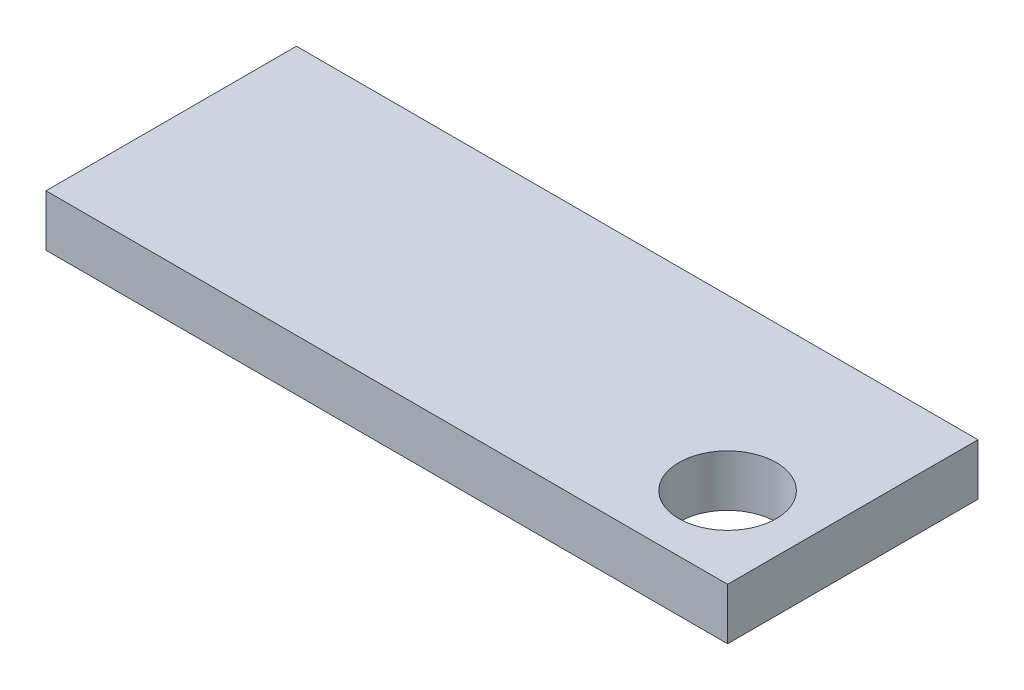
from build123d import *

# Parameters (mm, degrees)
SKETCH1_W             = 42
SKETCH1_H             = 15.43
BOSS_EXTRUDE1_DEPTH   = 1.5875
F_6_0MM_DOWEL_HOLE1_D = 6


with BuildPart() as part:
    # Sketch1 → Boss-Extrude1 (new body, symmetric)
    with BuildSketch(Plane(origin=(0, 0, 0), x_dir=(1, 0, 0), z_dir=(0, 1, 0))):
        with Locations((21, 7.715)):
            Rectangle(SKETCH1_W, SKETCH1_H)
    extrude(amount=BOSS_EXTRUDE1_DEPTH, both=True)

    # Ø6.0mm Dowel Hole1 (through all)
    with Locations(Plane(origin=(0, 1.5875, 0), x_dir=(1, 0, 0), z_dir=(0, 1, 0))):
        with Locations((37, 5)):
            Hole(F_6_0MM_DOWEL_HOLE1_D / 2)


solid = part.part
